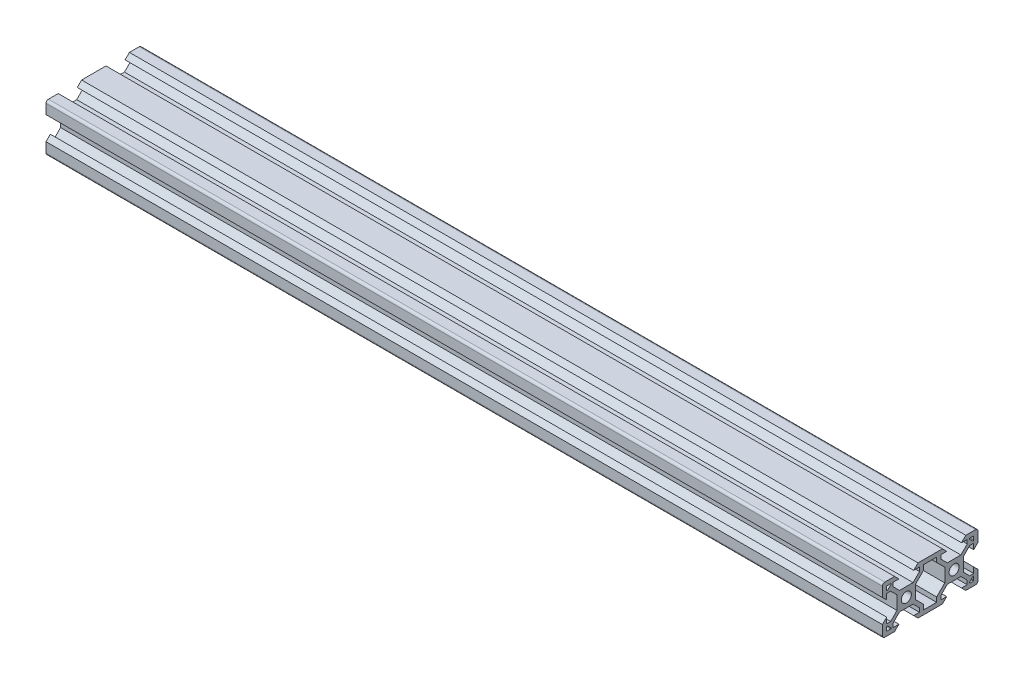
from build123d import *

# Parameters (mm, degrees)
SKETCH5_R           = 2.1
BOSS_EXTRUDE1_DEPTH = 175


with BuildPart() as part:
    # Sketch5 → Boss-Extrude1 (new body, symmetric)
    with BuildSketch(Plane(origin=(0, 0, 0), x_dir=(0, 0, -1), z_dir=(1, 0, 0))):
        with BuildLine():
            Line((-19.998019485, 4.9), (-18.198019485, 3.1))
            Line((-18.198019485, 3.1), (-18.198019485, 5.499339828))
            Line((-18.198019485, 5.499339828), (-16.558019485, 5.499339828))
            Line((-16.558019485, 5.499339828), (-13.9, 2.841320344))
            Line((-13.9, 2.841320344), (-13.9, -2.838679656))
            Line((-13.9, -2.838679656), (-16.558019485, -5.496699141))
            Line((-16.558019485, -5.496699141), (-18.198019485, -5.496699141))
            Line((-18.198019485, -5.496699141), (-18.198019485, -3.1))
            Line((-18.198019485, -3.1), (-19.998019485, -4.9))
            Line((-19.998019485, -4.9), (-19.998019485, -9))
            ThreePointArc((-19.998019485, -9), (-19.705126266, -9.707106781), (-18.998019485, -10))
            Line((-18.998019485, -10), (-14.9, -10))
            Line((-14.9, -10), (-13.1, -8.2))
            Line((-13.1, -8.2), (-15.5, -8.2))
            Line((-15.5, -8.2), (-15.5, -6.56))
            Line((-15.5, -6.56), (-12.84, -3.9))
            Line((-12.84, -3.9), (-7.16, -3.9))
            Line((-7.16, -3.9), (-4.5, -6.56))
            Line((-4.5, -6.56), (-4.5, -8.2))
            Line((-4.5, -8.2), (-6.9, -8.2))
            Line((-6.9, -8.2), (-5.1, -10))
            Line((-5.1, -10), (5.1, -10))
            Line((5.1, -10), (6.9, -8.2))
            Line((6.9, -8.2), (4.496038969, -8.2))
            Line((4.496038969, -8.2), (4.496038969, -6.56))
            Line((4.496038969, -6.56), (7.156038969, -3.9))
            Line((7.156038969, -3.9), (12.836038969, -3.9))
            Line((12.836038969, -3.9), (15.496038969, -6.56))
            Line((15.496038969, -6.56), (15.496038969, -8.2))
            Line((15.496038969, -8.2), (13.1, -8.2))
            Line((13.1, -8.2), (14.9, -10))
            Line((14.9, -10), (19.001980515, -10))
            ThreePointArc((19.001980515, -10), (19.709087297, -9.707106781), (20.001980515, -9))
            Line((20.001980515, -9), (20.001980515, -4.9))
            Line((20.001980515, -4.9), (18.201980515, -3.1))
            Line((18.201980515, -3.1), (18.201980515, -5.504621202))
            Line((18.201980515, -5.504621202), (16.561980515, -5.504621202))
            Line((16.561980515, -5.504621202), (13.9, -2.842640687))
            Line((13.9, -2.842640687), (13.9, 2.837359313))
            Line((13.9, 2.837359313), (16.561980515, 5.499339828))
            Line((16.561980515, 5.499339828), (18.201980515, 5.499339828))
            Line((18.201980515, 5.499339828), (18.201980515, 3.1))
            Line((18.201980515, 3.1), (20.001980515, 4.9))
            Line((20.001980515, 4.9), (20.001980515, 9))
            ThreePointArc((20.001980515, 9), (19.709087297, 9.707106781), (19.001980515, 10))
            Line((19.001980515, 10), (14.9, 10))
            Line((14.9, 10), (13.1, 8.2))
            Line((13.1, 8.2), (15.501320344, 8.2))
            Line((15.501320344, 8.2), (15.501320344, 6.56))
            Line((15.501320344, 6.56), (12.841320344, 3.9))
            Line((12.841320344, 3.9), (7.161320344, 3.9))
            Line((7.161320344, 3.9), (4.501320344, 6.56))
            Line((4.501320344, 6.56), (4.501320344, 8.2))
            Line((4.501320344, 8.2), (6.9, 8.2))
            Line((6.9, 8.2), (5.1, 10))
            Line((5.1, 10), (-5.1, 10))
            Line((-5.1, 10), (-6.9, 8.2))
            Line((-6.9, 8.2), (-4.501320344, 8.2))
            Line((-4.501320344, 8.2), (-4.501320344, 6.56))
            Line((-4.501320344, 6.56), (-7.161320344, 3.9))
            Line((-7.161320344, 3.9), (-12.841320344, 3.9))
            Line((-12.841320344, 3.9), (-15.501320344, 6.56))
            Line((-15.501320344, 6.56), (-15.501320344, 8.2))
            Line((-15.501320344, 8.2), (-13.1, 8.2))
            Line((-13.1, 8.2), (-14.9, 10))
            Line((-14.9, 10), (-18.998019485, 10))
            ThreePointArc((-18.998019485, 10), (-19.705126266, 9.707106781), (-19.998019485, 9))
            Line((-19.998019485, 9), (-19.998019485, 4.9))
        make_face()
        with Locations((-10, 0)):
            Circle(SKETCH5_R, mode=Mode.SUBTRACT)
        with Locations((10, 0)):
            Circle(SKETCH5_R, mode=Mode.SUBTRACT)
        Polygon((6.1, -2.84), (6.1, 2.84), (2.7, 6.24), (2.7, 8.2), (-2.7, 8.2), (-2.7, 6.24), (-6.1, 2.84), (-6.1, -2.84), (-2.7, -6.24), (-2.7, -8.2), (2.7, -8.2), (2.7, -6.24), align=None, mode=Mode.SUBTRACT)
        with BuildLine():
            Line((16.571320344, 8.2), (18.001980515, 8.2))
            ThreePointArc((18.001980515, 8.2), (18.143401872, 8.141421356), (18.201980515, 8))
            Line((18.201980515, 8), (18.201980515, 6.569339828))
            ThreePointArc((18.201980515, 6.569339828), (18.078517202, 6.384563922), (17.860559159, 6.427918472))
            Line((17.860559159, 6.427918472), (16.429898987, 7.858578644))
            ThreePointArc((16.429898987, 7.858578644), (16.386544437, 8.076536686), (16.571320344, 8.2))
        make_face(mode=Mode.SUBTRACT)
        with BuildLine():
            Line((16.571320344, -8.2), (18.001980515, -8.2))
            ThreePointArc((18.001980515, -8.2), (18.143401872, -8.141421356), (18.201980515, -8))
            Line((18.201980515, -8), (18.201980515, -6.569339828))
            ThreePointArc((18.201980515, -6.569339828), (18.078517202, -6.384563922), (17.860559159, -6.427918472))
            Line((17.860559159, -6.427918472), (16.429898987, -7.858578644))
            ThreePointArc((16.429898987, -7.858578644), (16.386544437, -8.076536686), (16.571320344, -8.2))
        make_face(mode=Mode.SUBTRACT)
        with BuildLine():
            Line((-17.860559159, 6.427918472), (-16.429898987, 7.858578644))
            ThreePointArc((-16.429898987, 7.858578644), (-16.386544437, 8.076536686), (-16.571320344, 8.2))
            Line((-16.571320344, 8.2), (-18.001980515, 8.2))
            ThreePointArc((-18.001980515, 8.2), (-18.143401872, 8.141421356), (-18.201980515, 8))
            Line((-18.201980515, 8), (-18.201980515, 6.569339828))
            ThreePointArc((-18.201980515, 6.569339828), (-18.078517202, 6.384563922), (-17.860559159, 6.427918472))
        make_face(mode=Mode.SUBTRACT)
        with BuildLine():
            Line((-16.571320344, -8.2), (-18.001980515, -8.2))
            ThreePointArc((-18.001980515, -8.2), (-18.143401872, -8.141421356), (-18.201980515, -8))
            Line((-18.201980515, -8), (-18.201980515, -6.569339828))
            ThreePointArc((-18.201980515, -6.569339828), (-18.078517202, -6.384563922), (-17.860559159, -6.427918472))
            Line((-17.860559159, -6.427918472), (-16.429898987, -7.858578644))
            ThreePointArc((-16.429898987, -7.858578644), (-16.386544437, -8.076536686), (-16.571320344, -8.2))
        make_face(mode=Mode.SUBTRACT)
    extrude(amount=BOSS_EXTRUDE1_DEPTH, both=True)


solid = part.part
